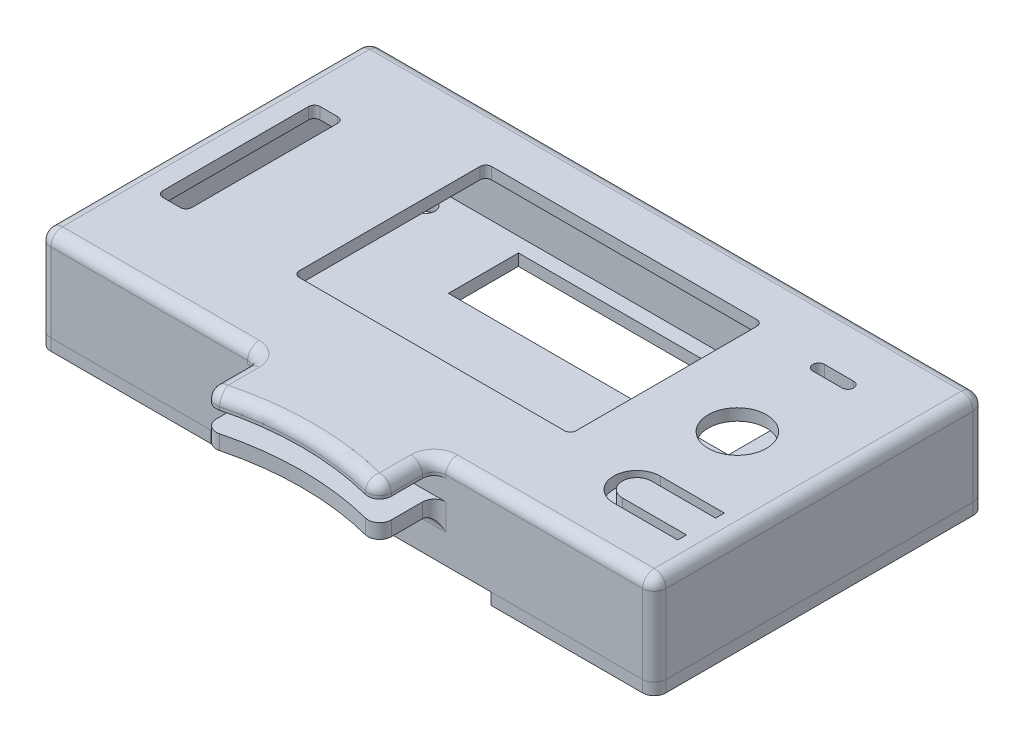
from build123d import *

# Parameters (mm, degrees)
CROQUIS1_W               = 105.5
CROQUIS1_H               = 56.7
CROQUIS1_R               = 5
CROQUIS1_W_2             = 47.5
CROQUIS1_H_2             = 33
CROQUIS1_W_3             = 5
CROQUIS1_H_3             = 27
SALIENTE_EXTRUIR1_DEPTH  = 2
CROQUIS5_W               = 105.5
CROQUIS5_H               = 56.7
CROQUIS5_W_2             = 102.5
CROQUIS5_H_2             = 53.7
SALIENTE_EXTRUIR4_DEPTH  = 13.5
CROQUIS6_R               = 1.6
CROQUIS6_R_2             = 1.55
CROQUIS6_W               = 7
CROQUIS6_H               = 45
CROQUIS6_W_2             = 48
CROQUIS6_H_2             = 12
SALIENTE_EXTRUIR5_DEPTH  = 2
CROQUIS8_W               = 6.15
CROQUIS8_H               = 7
SALIENTE_EXTRUIR13_DEPTH = 9
CROQUIS9_R               = 2.15
CORTAR_EXTRUIR2_DEPTH    = 3.5
REDONDEO6_R              = 1
REDONDEO7_R              = 1
CROQUIS10_R              = 2.5
SALIENTE_EXTRUIR14_DEPTH = 2
CROQUIS13_W              = 30
CROQUIS13_H              = 2.5
SALIENTE_EXTRUIR16_DEPTH = 10
CORTAR_EXTRUIR3_DEPTH    = 8.5
REDONDEO8_R              = 2
REDONDEO9_R              = 2


with BuildPart() as part:
    # Croquis1 → Saliente-Extruir1 (new body)
    with BuildSketch(Plane(origin=(0, 0, 0), x_dir=(1, 0, 0), z_dir=(0, 1, 0))):
        with Locations((50.5, 26.1)):
            Rectangle(CROQUIS1_W, CROQUIS1_H)
        with Locations((88.05, 27.2)):
            Circle(CROQUIS1_R, mode=Mode.SUBTRACT)
        with Locations((50.35, 29)):
            Rectangle(CROQUIS1_W_2, CROQUIS1_H_2, mode=Mode.SUBTRACT)
        with Locations((5.5, 26.2)):
            Rectangle(CROQUIS1_W_3, CROQUIS1_H_3, mode=Mode.SUBTRACT)
        with BuildLine():
            Line((88.05, 12.48), (99.05, 12.48))
            Line((99.05, 12.48), (99.05, 13.98))
            Line((99.05, 13.98), (88.05, 13.98))
            ThreePointArc((88.05, 13.98), (84.05, 9.98), (88.05, 5.98))
            Line((88.05, 5.98), (99.05, 5.98))
            Line((99.05, 5.98), (99.05, 7.48))
            Line((99.05, 7.48), (88.05, 7.48))
            ThreePointArc((88.05, 7.48), (85.55, 9.98), (88.05, 12.48))
        make_face(mode=Mode.SUBTRACT)
        with BuildLine():
            Line((90.55, 42.65), (85.55, 42.65))
            ThreePointArc((85.55, 42.65), (84.55, 43.65), (85.55, 44.65))
            Line((85.55, 44.65), (90.55, 44.65))
            ThreePointArc((90.55, 44.65), (91.55, 43.65), (90.55, 42.65))
        make_face(mode=Mode.SUBTRACT)
    extrude(amount=SALIENTE_EXTRUIR1_DEPTH)

    # Croquis5 → Saliente-Extruir4 (add)
    with BuildSketch(Plane.XZ):
        with Locations((50.5, -26.1)):
            Rectangle(CROQUIS5_W, CROQUIS5_H)
        with Locations((50.5, -26.1)):
            Rectangle(CROQUIS5_W_2, CROQUIS5_H_2, mode=Mode.SUBTRACT)
    extrude(amount=SALIENTE_EXTRUIR4_DEPTH)

    # Croquis6 → Saliente-Extruir5 (add)
    with BuildSketch(Plane.XZ.offset(13.5)):
        Polygon((103.25, 2.25), (103.25, -54.45), (-2.25, -54.45), (-2.25, 2.25), (27.25, 2.25), (27.25, -3.75), (75.25, -3.75), (75.25, 2.25), align=None)
        with Locations((12.3, -49.5)):
            Circle(CROQUIS6_R, mode=Mode.SUBTRACT)
        with Locations((98.3, -2.7)):
            Circle(CROQUIS6_R, mode=Mode.SUBTRACT)
        with Locations((98.3, -49.5)):
            Circle(CROQUIS6_R, mode=Mode.SUBTRACT)
        with Locations((12.3, -2.7)):
            Circle(CROQUIS6_R, mode=Mode.SUBTRACT)
        with Locations((80.5, -26.1)):
            Circle(CROQUIS6_R_2, mode=Mode.SUBTRACT)
        with Locations((20.5, -26.1)):
            Circle(CROQUIS6_R_2, mode=Mode.SUBTRACT)
        with Locations((5.95, -26.45)):
            Rectangle(CROQUIS6_W, CROQUIS6_H, mode=Mode.SUBTRACT)
        with Locations((51.25, -44.45)):
            Rectangle(CROQUIS6_W_2, CROQUIS6_H_2, mode=Mode.SUBTRACT)
    extrude(amount=SALIENTE_EXTRUIR5_DEPTH)

    # Croquis8 → Saliente-Extruir13 (add)
    with BuildSketch(Plane.XZ):
        with Locations((12.3, -2.75)):
            Rectangle(CROQUIS8_W, CROQUIS8_H)
        with Locations((98.675, -2.75)):
            Rectangle(CROQUIS8_W, CROQUIS8_H)
        with Locations((12.3, -49.45)):
            Rectangle(CROQUIS8_W, CROQUIS8_H)
        with Locations((98.675, -49.45)):
            Rectangle(CROQUIS8_W, CROQUIS8_H)
    extrude(amount=SALIENTE_EXTRUIR13_DEPTH)

    # Croquis9 → Cortar-Extruir2 (cut)
    with BuildSketch(Plane.XZ.offset(9)):
        with Locations((12.3, -2.7)):
            Circle(CROQUIS9_R)
        with Locations((98.3, -2.7)):
            Circle(CROQUIS9_R)
        with Locations((98.3, -49.5)):
            Circle(CROQUIS9_R)
        with Locations((12.3, -49.5)):
            Circle(CROQUIS9_R)
    extrude(amount=-CORTAR_EXTRUIR2_DEPTH, mode=Mode.SUBTRACT)


with BuildPart() as body_2:
    # Partir1: the piece on the far side of the plane
    add(part.part)
    split(bisect_by=Plane(origin=(0, -13.5, 0), x_dir=(0, 0, -1), z_dir=(0, -1, 0)), keep=Keep.BOTTOM)

    # Redondeo6
    redondeo6_edges = [body_2.edges().sort_by_distance(p)[0] for p in [
        (3, 1, -39.7),
        (8, 1, -39.7),
        (8, 1, -12.7),
        (3, 1, -12.7),
        (26.6, 1, -45.5),
        (74.1, 1, -45.5),
        (74.1, 1, -12.5),
        (26.6, 1, -12.5),
    ]]
    fillet(redondeo6_edges, radius=REDONDEO6_R)

    # Redondeo7
    redondeo7_edges = [body_2.edges().sort_by_distance(p)[0] for p in [
        (95.6, 0, -2.615),
        (100.4, 0, -6.25),
        (101.75, -4.5, -6.25),
        (95.6, -4.5, 0.75),
        (98.675, 0, -45.95),
        (95.6, 0, -49.45),
        (95.6, -4.5, -52.95),
        (101.75, -4.5, -45.95),
        (9.225, 0, -49.45),
        (15.375, 0, -49.45),
        (12.3, 0, -45.95),
        (15.375, -4.5, -52.95),
        (9.225, -4.5, -52.95),
        (9.225, 0, -2.75),
        (12.3, 0, -6.25),
        (15.375, 0, -2.75),
        (15.375, -4.5, 0.75),
        (9.225, -4.5, 0.75),
    ]]
    fillet(redondeo7_edges, radius=REDONDEO7_R)

    # Croquis10 → Saliente-Extruir14 (add)
    with BuildSketch(Plane.XZ):
        with Locations((88.05, -9.98)):
            Circle(CROQUIS10_R)
    extrude(amount=SALIENTE_EXTRUIR14_DEPTH)

    # Croquis13 → Saliente-Extruir16 (add)
    with BuildSketch(Plane.XY.offset(2.25)):
        with Locations((50.5, 0.75)):
            Rectangle(CROQUIS13_W, CROQUIS13_H)
        with Locations((50.5, -5.25)):
            Rectangle(CROQUIS13_W, CROQUIS13_H)
    extrude(amount=SALIENTE_EXTRUIR16_DEPTH)

    # Croquis14 → Cortar-Extruir3 (cut)
    with BuildSketch(Plane(origin=(0, 2, 0), x_dir=(1, 0, 0), z_dir=(0, 1, 0))):
        with BuildLine():
            Line((65.5, -12.25), (35.5, -12.25))
            ThreePointArc((35.5, -12.25), (50.5, -9.946960071), (65.5, -12.25))
        make_face()
    extrude(amount=-CORTAR_EXTRUIR3_DEPTH, mode=Mode.SUBTRACT)

    # Redondeo8
    redondeo8_edges = [body_2.edges().sort_by_distance(p)[0] for p in [
        (84.375, 2, 2.25),
        (35.5, 0.75, 2.25),
        (35.5, 2, 7.25),
        (65.5, 0.75, 2.25),
        (65.5, 2, 7.25),
        (35.5, 0.75, 12.25),
        (65.5, 0.75, 12.25),
        (35.5, -5.25, 2.25),
        (50.5, -6.5, 2.25),
        (65.5, -5.25, 2.25),
        (35.5, -5.25, 12.25),
        (65.5, -5.25, 12.25),
        (50.5, 2, 9.946960071),
        (-2.25, 2, -26.1),
        (16.625, 2, 2.25),
        (103.25, 2, -26.1),
        (50.5, 2, -54.45),
        (-2.25, -5.75, -54.45),
        (103.25, -5.75, -54.45),
        (103.25, -5.75, 2.25),
        (-2.25, -5.75, 2.25),
    ]]
    fillet(redondeo8_edges, radius=REDONDEO8_R)


with BuildPart() as part_1:
    add(part.part)

    # Partir1
    split(bisect_by=Plane(origin=(0, -13.5, 0), x_dir=(0, 0, -1), z_dir=(0, -1, 0)), keep=Keep.TOP)

    # Redondeo9
    redondeo9_edges = [part_1.edges().sort_by_distance(p)[0] for p in [
        (103.25, -14.5, -54.45),
        (-2.25, -14.5, -54.45),
        (103.25, -14.5, 2.25),
        (-2.25, -14.5, 2.25),
    ]]
    fillet(redondeo9_edges, radius=REDONDEO9_R)


solid = Compound([body_2.part, part_1.part])
